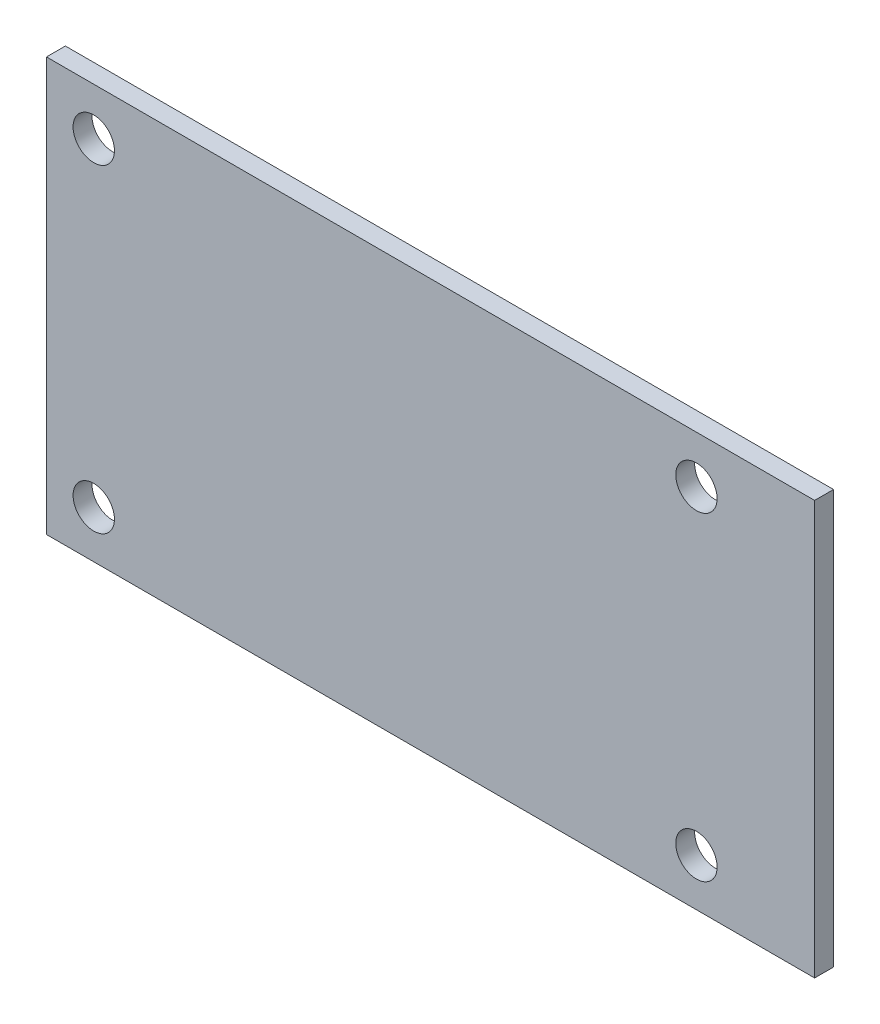
from build123d import *

# Parameters (mm, degrees)
SKETCH2_W           = 65
SKETCH2_H           = 35
BOSS_EXTRUDE1_DEPTH = 1.6
SKETCH3_R           = 1.75
CUT_EXTRUDE1_DEPTH  = 1.6


with BuildPart() as part:
    # Sketch2 → Boss-Extrude1 (new body)
    with BuildSketch(Plane.XY):
        Rectangle(SKETCH2_W, SKETCH2_H)
    extrude(amount=BOSS_EXTRUDE1_DEPTH)

    # Sketch3 → Cut-Extrude1 (cut)
    with BuildSketch(Plane.XY.offset(1.6)):
        with Locations((-28.5, 13.5)):
            Circle(SKETCH3_R)
        with Locations((-28.5, -13.5)):
            Circle(SKETCH3_R)
        with Locations((22.5, 13.5)):
            Circle(SKETCH3_R)
        with Locations((22.5, -13.5)):
            Circle(SKETCH3_R)
    extrude(amount=-CUT_EXTRUDE1_DEPTH, mode=Mode.SUBTRACT)


solid = part.part
